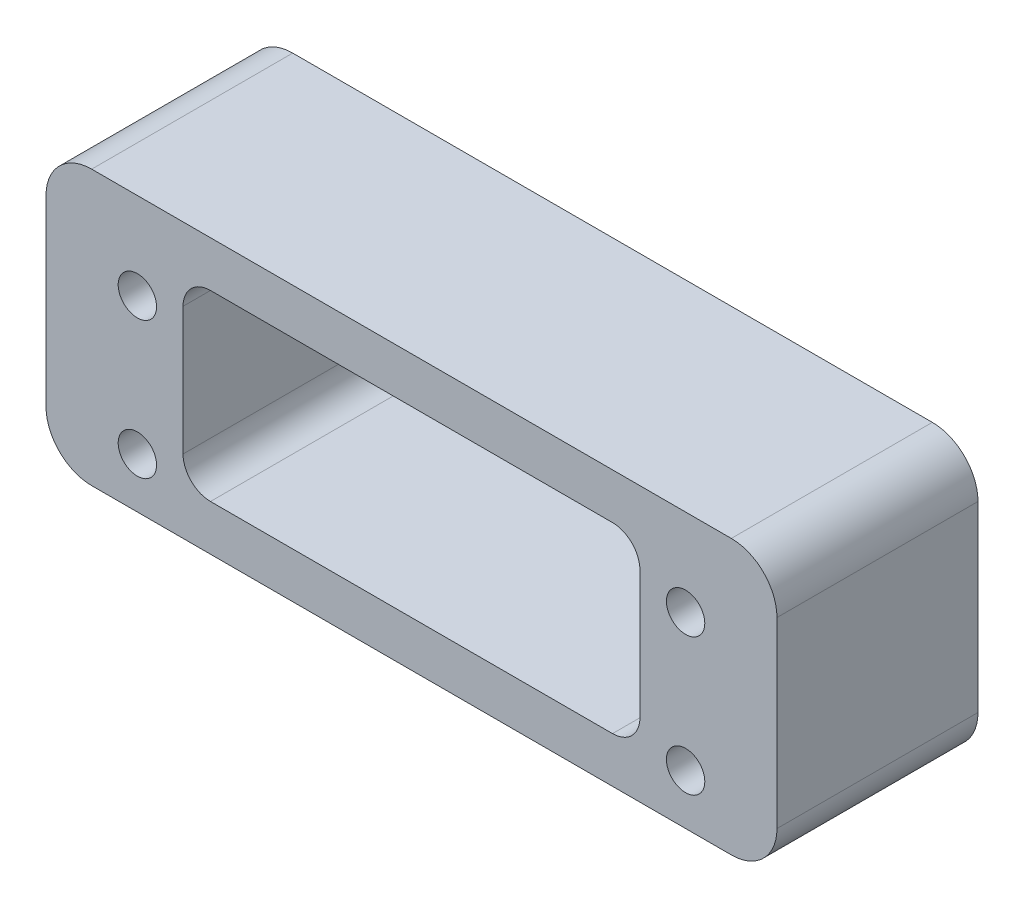
from build123d import *

# Parameters (mm, degrees)
SKETCH_1_W          = 80
SKETCH_1_H          = 30
EXTRUDE_1_DEPTH     = 11
FILLET_1_R          = 5
SKETCH_2_R          = 2.1
SKETCH_2_W          = 50
SKETCH_2_H          = 20
CUT_EXTRUDE_1_DEPTH = 23
FILLET_2_R          = 3


with BuildPart() as part:
    # 草图1 → 凸台-拉伸1 (new body, symmetric)
    with BuildSketch(Plane.XY):
        Rectangle(SKETCH_1_W, SKETCH_1_H)
    extrude(amount=EXTRUDE_1_DEPTH, both=True)

    # 圆角1
    fillet_1_edges = [part.edges().sort_by_distance(p)[0] for p in [
        (40, -15, 0),
        (-40, -15, 0),
        (-40, 15, 0),
        (40, 15, 0),
    ]]
    fillet(fillet_1_edges, radius=FILLET_1_R)

    # 草图2 → 切除-拉伸1 (cut, through all)
    with BuildSketch(Plane.XY.offset(11)):
        with Locations((-30, 5.5)):
            Circle(SKETCH_2_R)
        with Locations((30, 5.5)):
            Circle(SKETCH_2_R)
        with Locations((30, -9.5)):
            Circle(SKETCH_2_R)
        with Locations((-30, -9.5)):
            Circle(SKETCH_2_R)
        Rectangle(SKETCH_2_W, SKETCH_2_H)
    extrude(amount=-CUT_EXTRUDE_1_DEPTH, mode=Mode.SUBTRACT)

    # 圆角2
    fillet_2_edges = [part.edges().sort_by_distance(p)[0] for p in [
        (25, 10, 0),
        (25, -10, 0),
        (-25, -10, 0),
        (-25, 10, 0),
    ]]
    fillet(fillet_2_edges, radius=FILLET_2_R)


solid = part.part
